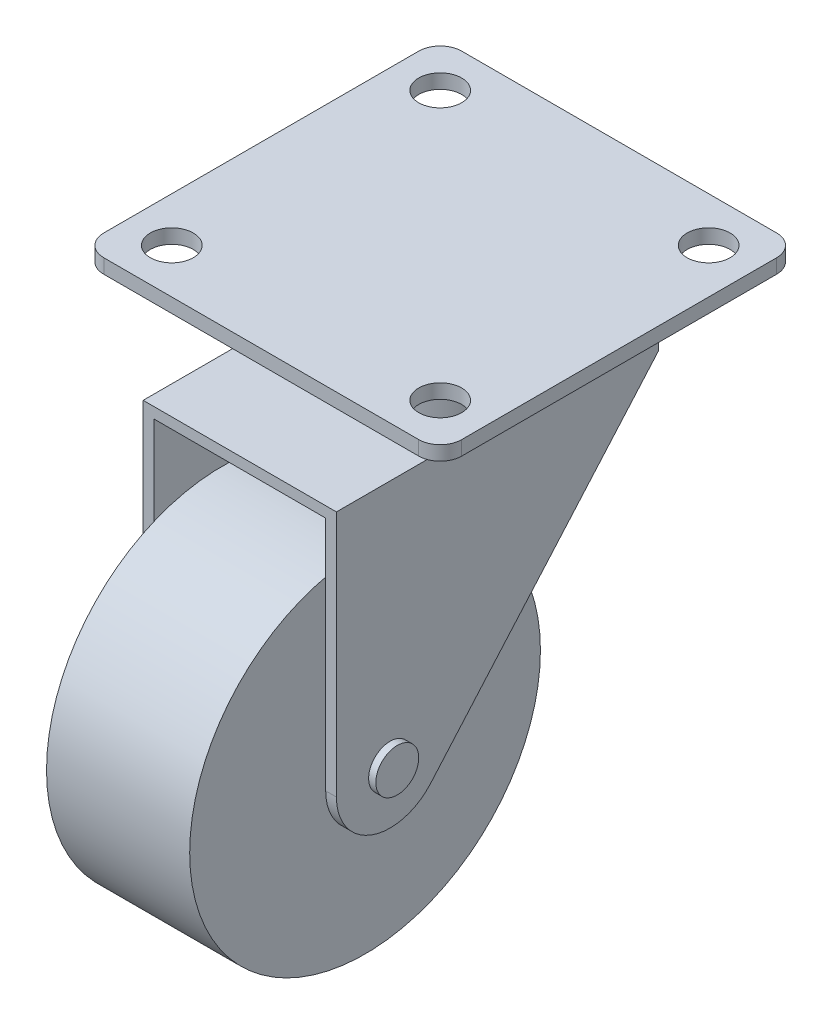
from build123d import *

# Parameters (mm, degrees)
SKETCH1_R                = 3
BOSS_EXTRUDE1_DEPTH      = 2
BOSS_EXTRUDE2_DEPTH      = 28
BOSS_EXTRUDE2_DEPTH_BACK = 17
SKETCH3_OUTSIDE_W        = 73.078
SKETCH3_OUTSIDE_H        = 73.578
CUT_EXTRUDE1_DEPTH       = 26
CUT_EXTRUDE1_DEPTH_BACK  = 26
SKETCH4_R                = 3
BOSS_EXTRUDE3_DEPTH      = 1
BOSS_EXTRUDE3_DEPTH_BACK = 28
SKETCH5_R                = 24.5
BOSS_EXTRUDE4_DEPTH      = 10
SKETCH6_R                = 13.5
BOSS_EXTRUDE5_DEPTH      = 9.5


with BuildPart() as part:
    # Sketch1 → Boss-Extrude1 (new body)
    with BuildSketch(Plane(origin=(0, 0, 0), x_dir=(1, 0, 0), z_dir=(0, 1, 0))):
        with BuildLine():
            Line((-22, -25), (22, -25))
            ThreePointArc((22, -25), (24.121320344, -24.121320344), (25, -22))
            Line((25, -22), (25, 22))
            ThreePointArc((25, 22), (24.121320344, 24.121320344), (22, 25))
            Line((22, 25), (-22, 25))
            ThreePointArc((-22, 25), (-24.121320344, 24.121320344), (-25, 22))
            Line((-25, 22), (-25, -22))
            ThreePointArc((-25, -22), (-24.121320344, -24.121320344), (-22, -25))
        make_face()
        with Locations((18.75, 18.75)):
            Circle(SKETCH1_R, mode=Mode.SUBTRACT)
        with Locations((18.75, -18.75)):
            Circle(SKETCH1_R, mode=Mode.SUBTRACT)
        with Locations((-18.75, -18.75)):
            Circle(SKETCH1_R, mode=Mode.SUBTRACT)
        with Locations((-18.75, 18.75)):
            Circle(SKETCH1_R, mode=Mode.SUBTRACT)
    extrude(amount=-BOSS_EXTRUDE1_DEPTH)



with BuildPart() as body_2:
    # Sketch2 → Boss-Extrude2 (new body, two sides)
    with BuildSketch(Plane.XY) as boss_extrude2_sk:
        Polygon((13.5, -53.5), (13.5, -11.5), (-13.5, -11.5), (-13.5, -53.5), (-12, -53.5), (-12, -13), (12, -13), (12, -53.5), align=None)
    extrude(amount=BOSS_EXTRUDE2_DEPTH)
    extrude(boss_extrude2_sk.sketch, amount=-BOSS_EXTRUDE2_DEPTH_BACK)

    # Sketch3 outside → Cut-Extrude1 (cut, two sides)
    with BuildSketch(Plane(origin=(0, 0, 0), x_dir=(0, 0, -1), z_dir=(1, 0, 0))) as cut_extrude1_sk:
        with Locations((-1.5, -26.75)):
            Rectangle(SKETCH3_OUTSIDE_W, SKETCH3_OUTSIDE_H)
        with BuildLine():
            Line((17, -11.5), (17, -14.5))
            Line((17, -14.5), (-14.853504945, -50.936303637))
            ThreePointArc((-14.853504945, -50.936303637), (-23.136407318, -53.021350045), (-28, -46))
            Line((-28, -46), (-28, -11.5))
            Line((-28, -11.5), (17, -11.5))
        make_face(mode=Mode.SUBTRACT)
    extrude(amount=CUT_EXTRUDE1_DEPTH, mode=Mode.SUBTRACT)
    extrude(cut_extrude1_sk.sketch, amount=-CUT_EXTRUDE1_DEPTH_BACK, mode=Mode.SUBTRACT)

    # Sketch4 → Boss-Extrude3 (add, two sides)
    with BuildSketch(Plane(origin=(13.5, 0, 0), x_dir=(0, 0, -1), z_dir=(1, 0, 0))) as boss_extrude3_sk:
        with Locations((-20.5, -46)):
            Circle(SKETCH4_R)
    extrude(amount=BOSS_EXTRUDE3_DEPTH)
    extrude(boss_extrude3_sk.sketch, amount=-BOSS_EXTRUDE3_DEPTH_BACK)


with BuildPart() as body_3:
    # Sketch5 → Boss-Extrude4 (new body, symmetric)
    with BuildSketch(Plane(origin=(0, 0, 0), x_dir=(0, 0, -1), z_dir=(1, 0, 0))):
        with Locations((-20.5, -46)):
            Circle(SKETCH5_R)
    extrude(amount=BOSS_EXTRUDE4_DEPTH, both=True)


with BuildPart() as part_1:
    add(part.part)

    add(body_2.part)  # Boss-Extrude5 merges body 2
    # Sketch6 → Boss-Extrude5 (add)
    with BuildSketch(Plane(origin=(0, -11.5, 0), x_dir=(1, 0, 0), z_dir=(0, 1, 0))):
        Circle(SKETCH6_R)
    extrude(amount=BOSS_EXTRUDE5_DEPTH)


solid = Compound([body_3.part, part_1.part])
